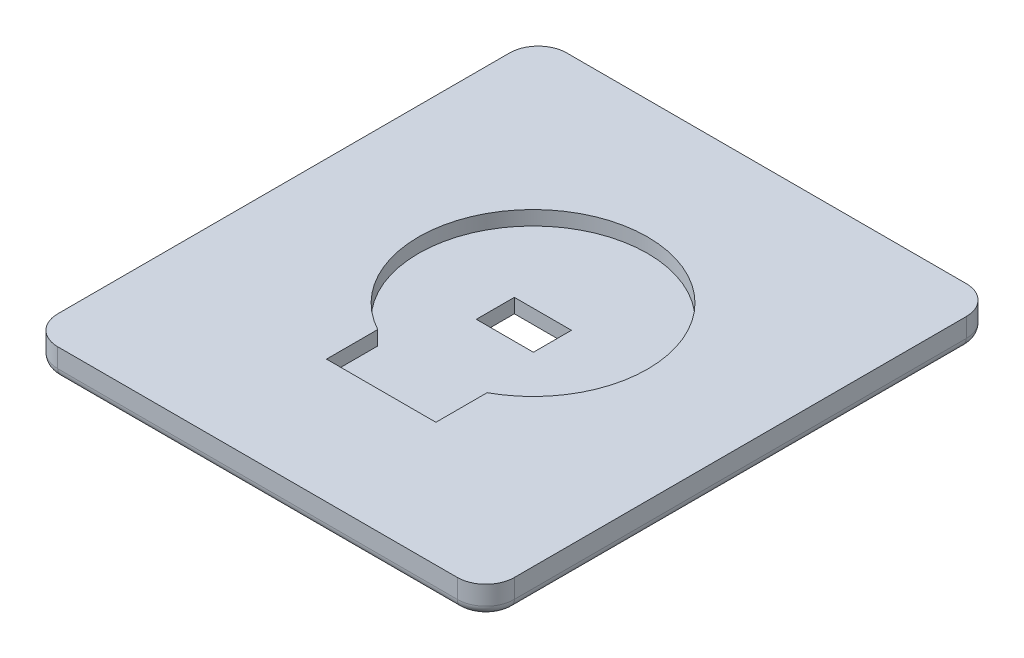
from build123d import *

# Parameters (mm, degrees)
SKETCH1_W           = 42
SKETCH1_H           = 47.5
BOSS_EXTRUDE1_DEPTH = 3
CUT_EXTRUDE2_DEPTH  = 1.5
SKETCH3_W           = 6
SKETCH3_H           = 4
CUT_EXTRUDE3_DEPTH  = 5
SKETCH4_W           = 48
SKETCH4_H           = 53.5
SKETCH4_W_2         = 42
SKETCH4_H_2         = 47.5
BOSS_EXTRUDE2_DEPTH = 3
FILLET1_R           = 3
FILLET2_R           = 1


with BuildPart() as part:
    # Sketch1 → Boss-Extrude1 (new body)
    with BuildSketch(Plane(origin=(0, 0, 0), x_dir=(1, 0, 0), z_dir=(0, 1, 0))):
        Rectangle(SKETCH1_W, SKETCH1_H)
    extrude(amount=BOSS_EXTRUDE1_DEPTH)

    # Sketch2 → Cut-Extrude2 (cut)
    with BuildSketch(Plane(origin=(0, 3, 0), x_dir=(1, 0, 0), z_dir=(0, 1, 0))):
        with BuildLine():
            ThreePointArc((12.038461538, 2.211538462), (-6.152373622, 12.559139876), (-5.75, -8.364947543))
            Line((-5.75, -8.364947543), (-5.75, -7.75))
            Line((-5.75, -7.75), (5.75, -7.75))
            Line((5.75, -7.75), (5.75, -8.364947543))
            ThreePointArc((5.75, -8.364947543), (10.347601414, -3.94083516), (12.038461538, 2.211538462))
        make_face()
        with BuildLine():
            Line((-5.75, -7.75), (-5.75, -8.364947543))
            ThreePointArc((-5.75, -8.364947543), (0, -9.826923077), (5.75, -8.364947543))
            Line((5.75, -8.364947543), (5.75, -7.75))
            Line((5.75, -7.75), (-5.75, -7.75))
        make_face()
        with BuildLine():
            Line((-5.75, -8.364947543), (-5.75, -13.75))
            Line((-5.75, -13.75), (5.75, -13.75))
            Line((5.75, -13.75), (5.75, -8.364947543))
            ThreePointArc((5.75, -8.364947543), (0, -9.826923077), (-5.75, -8.364947543))
        make_face()
    extrude(amount=-CUT_EXTRUDE2_DEPTH, mode=Mode.SUBTRACT)

    # Sketch3 → Cut-Extrude3 (cut)
    with BuildSketch(Plane(origin=(0, 3, 0), x_dir=(1, 0, 0), z_dir=(0, 1, 0))):
        with Locations((0, 1.25)):
            Rectangle(SKETCH3_W, SKETCH3_H)
    extrude(amount=-CUT_EXTRUDE3_DEPTH, mode=Mode.SUBTRACT)

    # Sketch4 → Boss-Extrude2 (add)
    with BuildSketch(Plane(origin=(0, 0, 0), x_dir=(1, 0, 0), z_dir=(0, 1, 0))):
        Rectangle(SKETCH4_W, SKETCH4_H)
        Rectangle(SKETCH4_W_2, SKETCH4_H_2, mode=Mode.SUBTRACT)
    extrude(amount=BOSS_EXTRUDE2_DEPTH)

    # Fillet1
    fillet1_edges = [part.edges().sort_by_distance(p)[0] for p in [
        (-24, 1.5, -26.75),
        (-24, 1.5, 26.75),
        (24, 1.5, 26.75),
        (24, 1.5, -26.75),
    ]]
    fillet(fillet1_edges, radius=FILLET1_R)

    # Fillet2
    fillet2_edges = [part.edges().sort_by_distance(p)[0] for p in [
        (-24, 0, 0),
        (0, 0, -26.75),
        (24, 0, 0),
        (0, 0, 26.75),
        (-23.121320344, 0, 25.871320344),
        (23.121320344, 0, 25.871320344),
        (23.121320344, 0, -25.871320344),
        (-23.121320344, 0, -25.871320344),
    ]]
    fillet(fillet2_edges, radius=FILLET2_R)


solid = part.part
